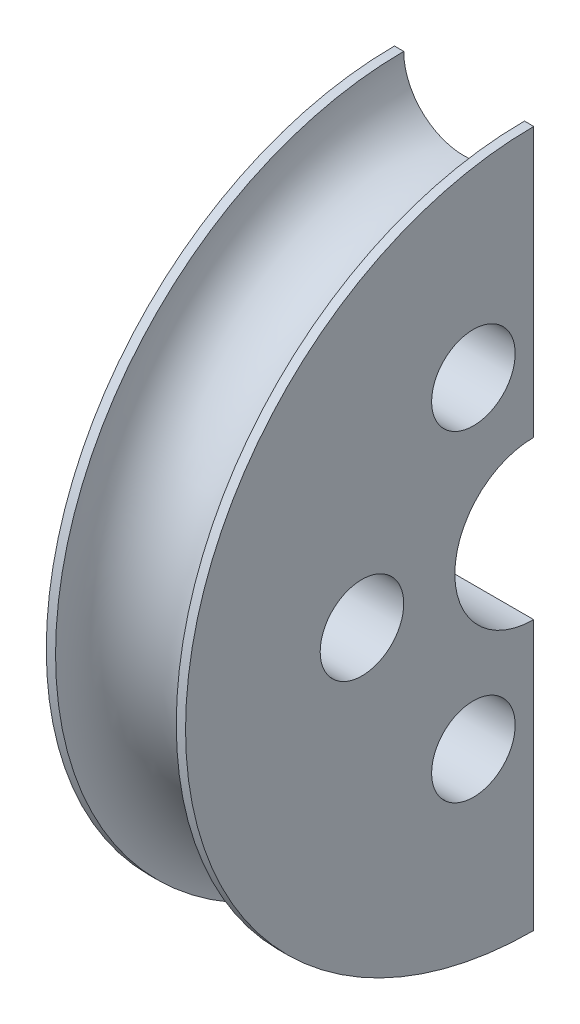
from build123d import *

# Parameters (mm, degrees)
R_VOLUTION1_ANGLE       = 180
ESQUISSE2_R             = 9
ENL_V_MAT_EXTRU_1_DEPTH = 31


with BuildPart() as part:
    # Esquisse1 → Révolution1 (revolve)
    with BuildSketch(Plane.XY):
        with BuildLine():
            Line((0, 17), (0, 75))
            Line((0, 75), (2, 75))
            ThreePointArc((2, 75), (15, 62), (28, 75))
            Line((28, 75), (30, 75))
            Line((30, 75), (30, 17))
            Line((30, 17), (0, 17))
        make_face()
    revolve(axis=Axis((0, 0, 0), (1, 0, 0)), revolution_arc=R_VOLUTION1_ANGLE)

    # Esquisse2 → Enlèv. mat.-Extru.1 (cut, through all)
    with BuildSketch(Plane.ZY):
        with Locations((37, 0)):
            Circle(ESQUISSE2_R)
        with Locations((13, -34.641016151)):
            Circle(ESQUISSE2_R)
        with Locations((13, 34.641016151)):
            Circle(ESQUISSE2_R)
    extrude(amount=-ENL_V_MAT_EXTRU_1_DEPTH, mode=Mode.SUBTRACT)


solid = part.part
